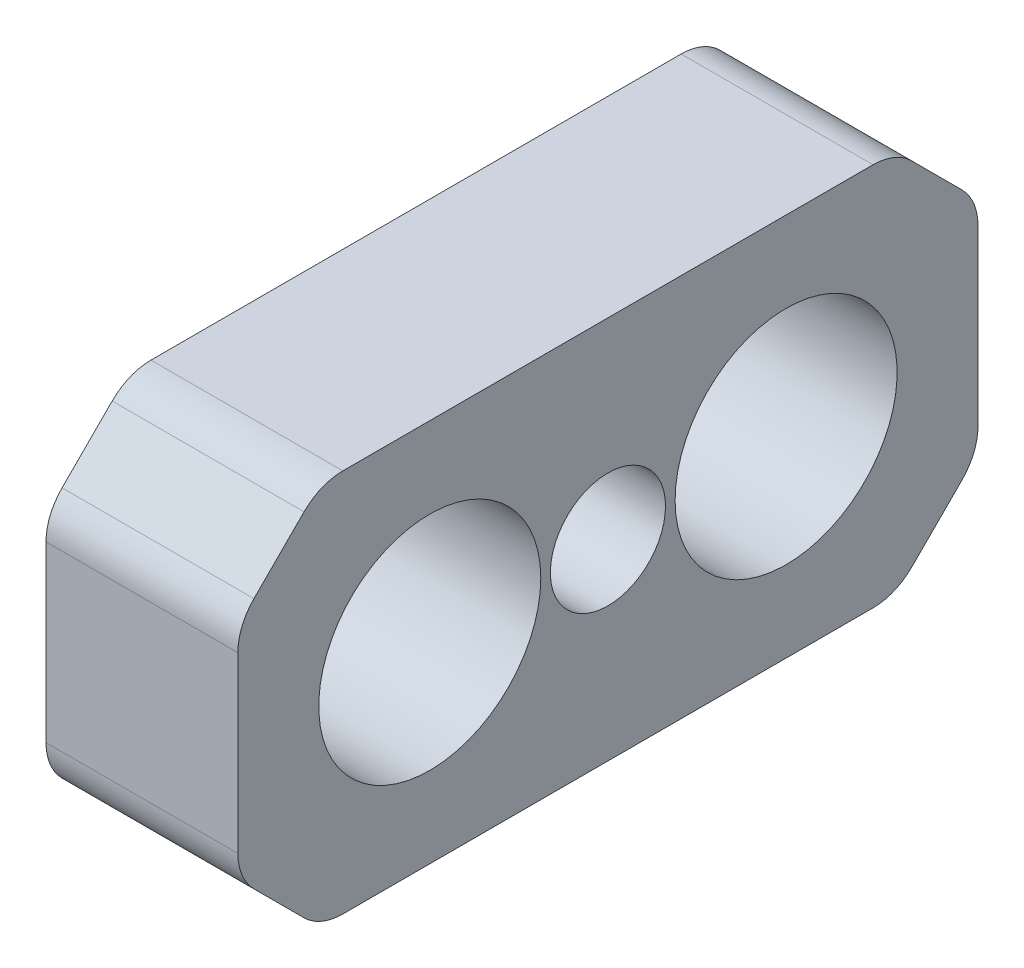
from build123d import *

# Parameters (mm, degrees)
SKETCH1_W           = 27
SKETCH1_H           = 14
SKETCH1_R           = 4.05
BOSS_EXTRUDE1_DEPTH = 7
SKETCH3_R           = 2.1
CUT_EXTRUDE4_DEPTH  = 5
CHANFREIN1_SIZE     = 3
CONG_1_R            = 2


with BuildPart() as part:
    # Sketch1 → Boss-Extrude1 (new body)
    with BuildSketch(Plane(origin=(0, 0, 0), x_dir=(0, 0, -1), z_dir=(1, 0, 0))):
        Rectangle(SKETCH1_W, SKETCH1_H)
        with Locations((-6.5, 0)):
            Circle(SKETCH1_R, mode=Mode.SUBTRACT)
        with Locations((6.5, 0)):
            Circle(SKETCH1_R, mode=Mode.SUBTRACT)
    extrude(amount=BOSS_EXTRUDE1_DEPTH)

    # Sketch3 → Cut-Extrude4 (cut)
    with BuildSketch(Plane(origin=(7, 0, 0), x_dir=(0, 0, -1), z_dir=(1, 0, 0))):
        Circle(SKETCH3_R)
    extrude(amount=-CUT_EXTRUDE4_DEPTH, mode=Mode.SUBTRACT)

    # Chanfrein1
    chanfrein1_edges = [part.edges().sort_by_distance(p)[0] for p in [
        (3.5, 7, 13.5),
        (3.5, 7, -13.5),
        (3.5, -7, -13.5),
        (3.5, -7, 13.5),
    ]]
    chamfer(chanfrein1_edges, length=CHANFREIN1_SIZE)

    # Congé1
    cong_1_edges = [part.edges().sort_by_distance(p)[0] for p in [
        (3.5, -4, 13.5),
        (3.5, 4, 13.5),
        (3.5, 7, -10.5),
        (3.5, 7, 10.5),
        (3.5, -7, -10.5),
        (3.5, -7, 10.5),
        (3.5, 4, -13.5),
        (3.5, -4, -13.5),
    ]]
    fillet(cong_1_edges, radius=CONG_1_R)


solid = part.part
